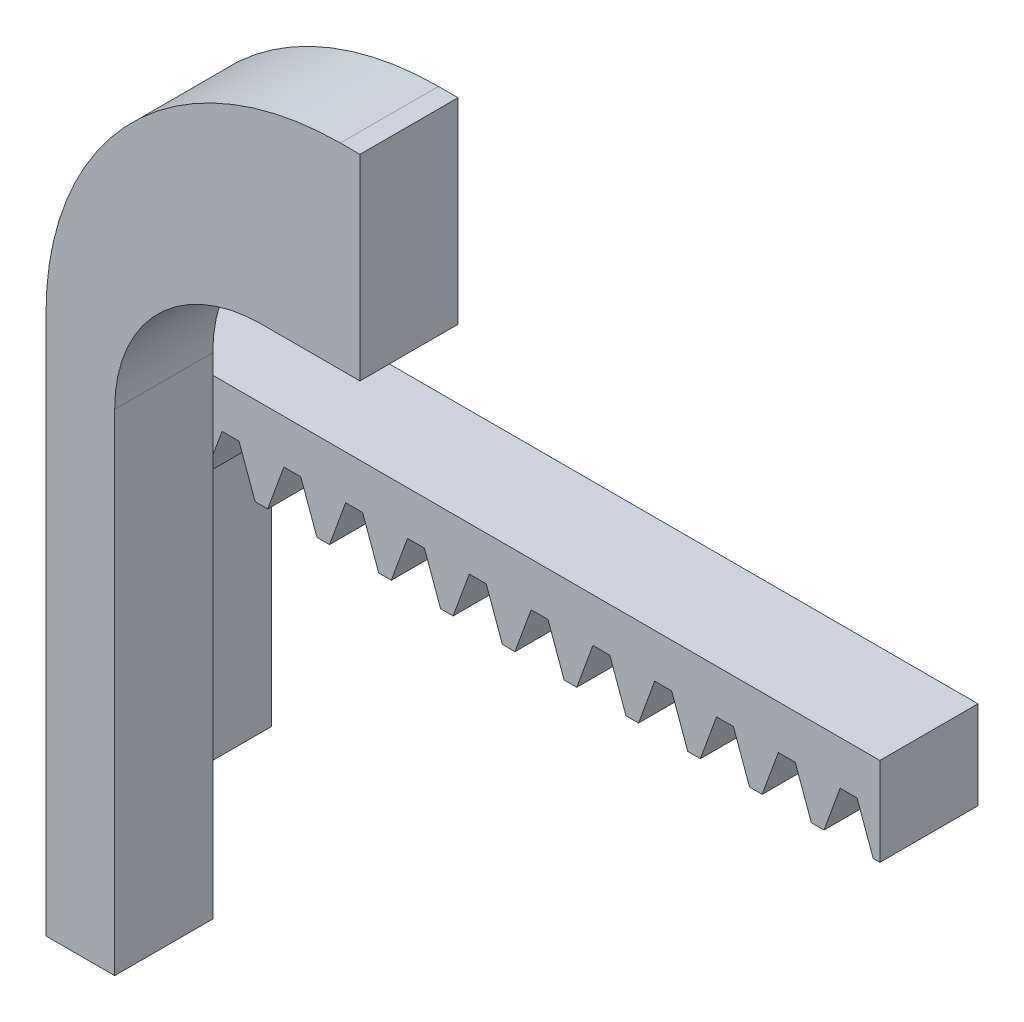
from build123d import *

# Parameters (mm, degrees)
BOSS_EXTRUDE1_DEPTH             = 10
SKIZZE2_W                       = 75
SKIZZE2_H                       = 9
AUFSATZ_LINEAR_AUSTRAGEN1_DEPTH = 10
SCHNITT_LINEAR_AUSTRAGEN2_DEPTH = 10
SKIZZE4_W                       = 20
SKIZZE4_H                       = 48
AUFSATZ_LINEAR_AUSTRAGEN2_DEPTH = 3
SKIZZE5_W                       = 10
SKIZZE5_H                       = 10
SCHNITT_LINEAR_AUSTRAGEN3_DEPTH = 10


with BuildPart() as part:
    # Sketch1 → Boss-Extrude1 (new body)
    with BuildSketch(Plane.XY):
        with BuildLine():
            Line((7, 0), (0, 0))
            Line((0, 0), (0, 47.7))
            Line((0, 47.7), (0, 55))
            ThreePointArc((0, 55), (8.786796564, 76.213203436), (30, 85))
            Line((30, 85), (32, 85))
            Line((32, 85), (32, 65))
            Line((32, 65), (22, 65))
            ThreePointArc((22, 65), (11.393398282, 60.606601718), (7, 50))
            Line((7, 50), (7, 0))
        make_face()
    extrude(amount=BOSS_EXTRUDE1_DEPTH)

    # Skizze2 → Aufsatz-Linear austragen1 (add)
    with BuildSketch(Plane(origin=(0, 0, 0), x_dir=(-1, 0, 0), z_dir=(0, 0, -1))):
        with Locations((-37.5, 43.5)):
            Rectangle(SKIZZE2_W, SKIZZE2_H)
    extrude(amount=AUFSATZ_LINEAR_AUSTRAGEN1_DEPTH)

    # Skizze3 → Schnitt-Linear austragen2 (cut)
    with BuildSketch(Plane(origin=(0, 0, -10), x_dir=(-1, 0, 0), z_dir=(0, 0, -1))):
        Polygon((-3.370852377, 43.5254), (-1.647110898, 43.5254), (0, 39), (-5.017963275, 39), align=None)
        Polygon((-9.670852377, 43.5254), (-7.947110898, 43.5254), (-6.3, 39), (-11.317963275, 39), align=None)
        Polygon((-15.970852377, 43.5254), (-14.247110898, 43.5254), (-12.6, 39), (-17.617963275, 39), align=None)
        Polygon((-22.270852377, 43.5254), (-20.547110898, 43.5254), (-18.9, 39), (-23.917963275, 39), align=None)
        Polygon((-28.570852377, 43.5254), (-26.847110898, 43.5254), (-25.2, 39), (-30.217963275, 39), align=None)
        Polygon((-34.870852377, 43.5254), (-33.147110898, 43.5254), (-31.5, 39), (-36.517963275, 39), align=None)
        Polygon((-41.170852377, 43.5254), (-39.447110898, 43.5254), (-37.8, 39), (-42.817963275, 39), align=None)
        Polygon((-47.470852377, 43.5254), (-45.747110898, 43.5254), (-44.1, 39), (-49.117963275, 39), align=None)
        Polygon((-53.770852377, 43.5254), (-52.047110898, 43.5254), (-50.4, 39), (-55.417963275, 39), align=None)
        Polygon((-60.070852377, 43.5254), (-58.347110898, 43.5254), (-56.7, 39), (-61.717963275, 39), align=None)
        Polygon((-66.370852377, 43.5254), (-64.647110898, 43.5254), (-63, 39), (-68.017963275, 39), align=None)
        Polygon((-72.670852377, 43.5254), (-70.947110898, 43.5254), (-69.3, 39), (-74.317963275, 39), align=None)
    extrude(amount=-SCHNITT_LINEAR_AUSTRAGEN2_DEPTH, mode=Mode.SUBTRACT)

    # Skizze4 → Aufsatz-Linear austragen2 (add)
    with BuildSketch(Plane.ZY):
        with Locations((0, 24)):
            Rectangle(SKIZZE4_W, SKIZZE4_H)
    extrude(amount=-AUFSATZ_LINEAR_AUSTRAGEN2_DEPTH)

    # Skizze5 → Schnitt-Linear austragen3 (cut)
    with BuildSketch(Plane(origin=(3, 0, 0), x_dir=(0, 0, -1), z_dir=(1, 0, 0))):
        with Locations((5, 5)):
            Rectangle(SKIZZE5_W, SKIZZE5_H)
    extrude(amount=-SCHNITT_LINEAR_AUSTRAGEN3_DEPTH, mode=Mode.SUBTRACT)


solid = part.part
